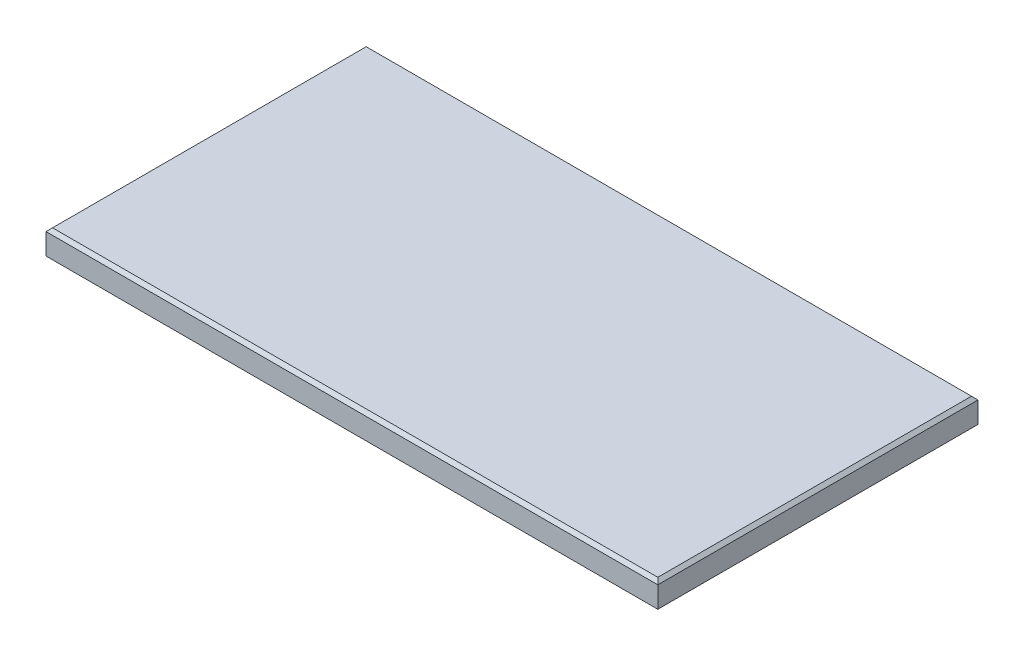
from build123d import *

# Parameters (mm, degrees)
SKETCH1_W           = 476.25
SKETCH1_H           = 249.2375
BOSS_EXTRUDE1_DEPTH = 19.05
CHAMFER1_SIZE       = 2.54


with BuildPart() as part:
    # Sketch1 → Boss-Extrude1 (new body)
    with BuildSketch(Plane(origin=(0, 0, 0), x_dir=(1, 0, 0), z_dir=(0, 1, 0))):
        with Locations((238.125, 124.61875)):
            Rectangle(SKETCH1_W, SKETCH1_H)
    extrude(amount=BOSS_EXTRUDE1_DEPTH)

    # Chamfer1
    chamfer1_edges = [part.edges().sort_by_distance(p)[0] for p in [
        (476.25, 19.05, -124.61875),
        (238.125, 19.05, -249.2375),
        (0, 19.05, -124.61875),
        (238.125, 19.05, 0),
    ]]
    chamfer(chamfer1_edges, length=CHAMFER1_SIZE)


solid = part.part
